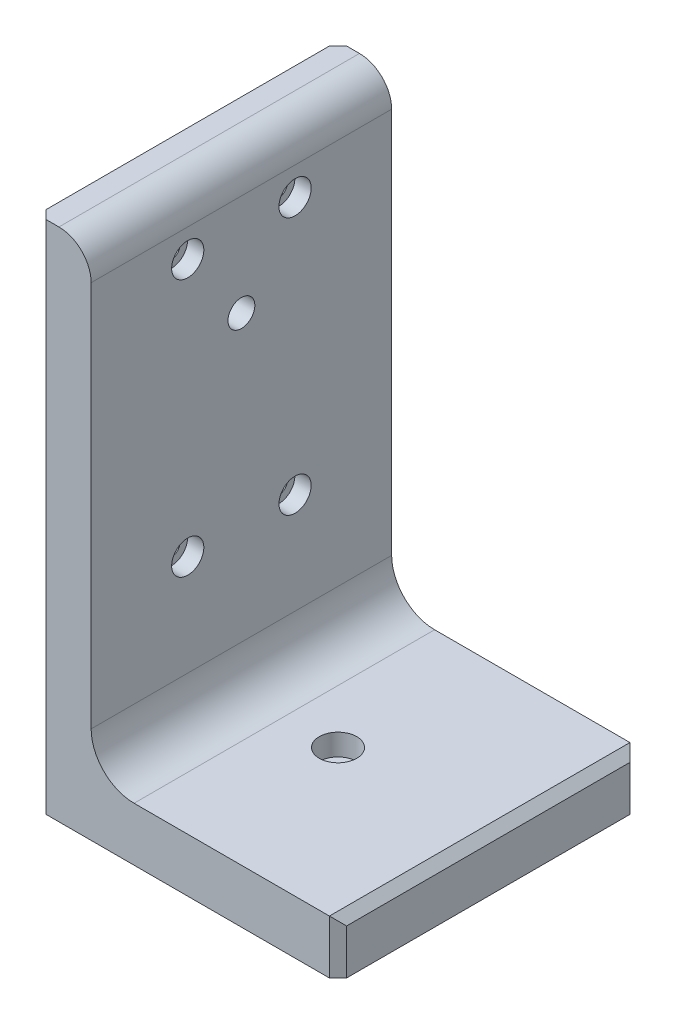
from build123d import *

# Parameters (mm, degrees)
BASESTEELANGLE_DEPTH                             = 44.45
F_3_8_16_TAPPED_HOLE1_D                          = 7.9375
CBORE_FOR_10_SOCKET_HEAD_CAP_SCREW2_D            = 5.1054
CBORE_FOR_10_SOCKET_HEAD_CAP_SCREW2_CBORE_D      = 9.525
CBORE_FOR_10_SOCKET_HEAD_CAP_SCREW2_CBORE_DEPTH  = 4.826
SKETCH16_W                                       = 94.308892356
SKETCH16_H                                       = 144.501300052
CUT_EXTRUDE1_DEPTH                               = 25.4
F_10_32_TAPPED_HOLE3_D                           = 4.0386
F_10_32_TAPPED_HOLE3_DEPTH                       = 13.6144
F_10_32_TAPPED_HOLE3_TIP                         = 1.213317848
F_10_32_TAPPED_HOLE4_D                           = 4.0386
F_10_32_TAPPED_HOLE4_DEPTH                       = 13.6144
F_10_32_TAPPED_HOLE4_TIP                         = 1.213317848
CBORE_FOR_1_4_SOCKET_HEAD_CAP_SCREW1_D           = 6.7564
CBORE_FOR_1_4_SOCKET_HEAD_CAP_SCREW1_CBORE_D     = 11.1125
CBORE_FOR_1_4_SOCKET_HEAD_CAP_SCREW1_CBORE_DEPTH = 6.35
SKETCH19_R                                       = 25.4
CUT_EXTRUDE2_DEPTH                               = 0.508
CHAMFER1_SIZE                                    = 2.54


with BuildPart() as part:
    # Sketch1 → BaseSteelAngle (new body, symmetric)
    with BuildSketch(Plane.XY):
        with BuildLine():
            Line((0, 0), (0, 152.4))
            Line((0, 152.4), (6.35508, 152.4))
            ThreePointArc((6.35508, 152.4), (13.086679988, 149.611679988), (15.875, 142.88008))
            Line((15.875, 142.88008), (15.875, 28.575))
            ThreePointArc((15.875, 28.575), (19.594743879, 19.594743879), (28.575, 15.875))
            Line((28.575, 15.875), (142.88008, 15.875))
            ThreePointArc((142.88008, 15.875), (149.611679988, 13.086679988), (152.4, 6.35508))
            Line((152.4, 6.35508), (152.4, 0))
            Line((152.4, 0), (0, 0))
        make_face()
    extrude(amount=BASESTEELANGLE_DEPTH, both=True)

    # 3/8-16 Tapped Hole1 (through all)
    with Locations(Plane.ZY):
        with Locations((0, 112.8903)):
            Hole(F_3_8_16_TAPPED_HOLE1_D / 2)

    # CBORE for #10 Socket Head Cap Screw2 (through all)
    with Locations(Plane(origin=(15.875, 58.160616164, 30.43670953), x_dir=(0, 0, 1), z_dir=(1, 0, 0))):
        with Locations((-46.31170953, -0.259383836), (-14.56170953, -0.259383836), (-14.56170953, -76.459383836), (-46.31170953, -76.459383836)):
            CounterBoreHole(CBORE_FOR_10_SOCKET_HEAD_CAP_SCREW2_D / 2, CBORE_FOR_10_SOCKET_HEAD_CAP_SCREW2_CBORE_D / 2, CBORE_FOR_10_SOCKET_HEAD_CAP_SCREW2_CBORE_DEPTH)

    # Sketch16 → Cut-Extrude1 (cut, symmetric)
    with BuildSketch(Plane(origin=(0, 0, 0), x_dir=(1, 0, 0), z_dir=(0, 1, 0))):
        with Locations((136.054446178, 1.452938118)):
            Rectangle(SKETCH16_W, SKETCH16_H)
    extrude(amount=CUT_EXTRUDE1_DEPTH, both=True, mode=Mode.SUBTRACT)

    # #10-32 Tapped Hole3
    with Locations(Plane.ZY):
        with Locations((-31.75, 82.55), (31.75, 82.55), (31.75, 19.05), (-31.75, 19.05)):
            Hole(F_10_32_TAPPED_HOLE3_D / 2, depth=F_10_32_TAPPED_HOLE3_DEPTH)
            with Locations((0, 0, -(F_10_32_TAPPED_HOLE3_DEPTH + F_10_32_TAPPED_HOLE3_TIP / 2))):  # 118° drill point
                Cone(0, F_10_32_TAPPED_HOLE3_D / 2, F_10_32_TAPPED_HOLE3_TIP, mode=Mode.SUBTRACT)

    # #10-32 Tapped Hole4
    with Locations(Plane.XZ):
        with Locations((76.2, 31.75), (12.7, 31.75), (12.7, -31.75), (76.2, -31.75)):
            Hole(F_10_32_TAPPED_HOLE4_D / 2, depth=F_10_32_TAPPED_HOLE4_DEPTH)
            with Locations((0, 0, -(F_10_32_TAPPED_HOLE4_DEPTH + F_10_32_TAPPED_HOLE4_TIP / 2))):  # 118° drill point
                Cone(0, F_10_32_TAPPED_HOLE4_D / 2, F_10_32_TAPPED_HOLE4_TIP, mode=Mode.SUBTRACT)

    # CBORE for 1/4 Socket Head Cap Screw1 (through all)
    with Locations(Plane(origin=(0, 15.875, 0), x_dir=(-1, 0, 0), z_dir=(0, 1, 0))):
        with Locations((-44.45, 0)):
            CounterBoreHole(CBORE_FOR_1_4_SOCKET_HEAD_CAP_SCREW1_D / 2, CBORE_FOR_1_4_SOCKET_HEAD_CAP_SCREW1_CBORE_D / 2, CBORE_FOR_1_4_SOCKET_HEAD_CAP_SCREW1_CBORE_DEPTH)

    # Sketch19 → Cut-Extrude2 (cut)
    with BuildSketch(Plane.XZ):
        with Locations((44.45, 0)):
            Circle(SKETCH19_R)
    extrude(amount=-CUT_EXTRUDE2_DEPTH, mode=Mode.SUBTRACT)

    # Chamfer1
    chamfer1_edges = [part.edges().sort_by_distance(p)[0] for p in [
        (0, 76.2, 44.45),
        (88.9, 7.9375, -44.45),
        (88.9, 7.9375, 44.45),
        (88.9, 15.875, 0),
        (0, 76.2, -44.45),
    ]]
    chamfer(chamfer1_edges, length=CHAMFER1_SIZE)


solid = part.part
